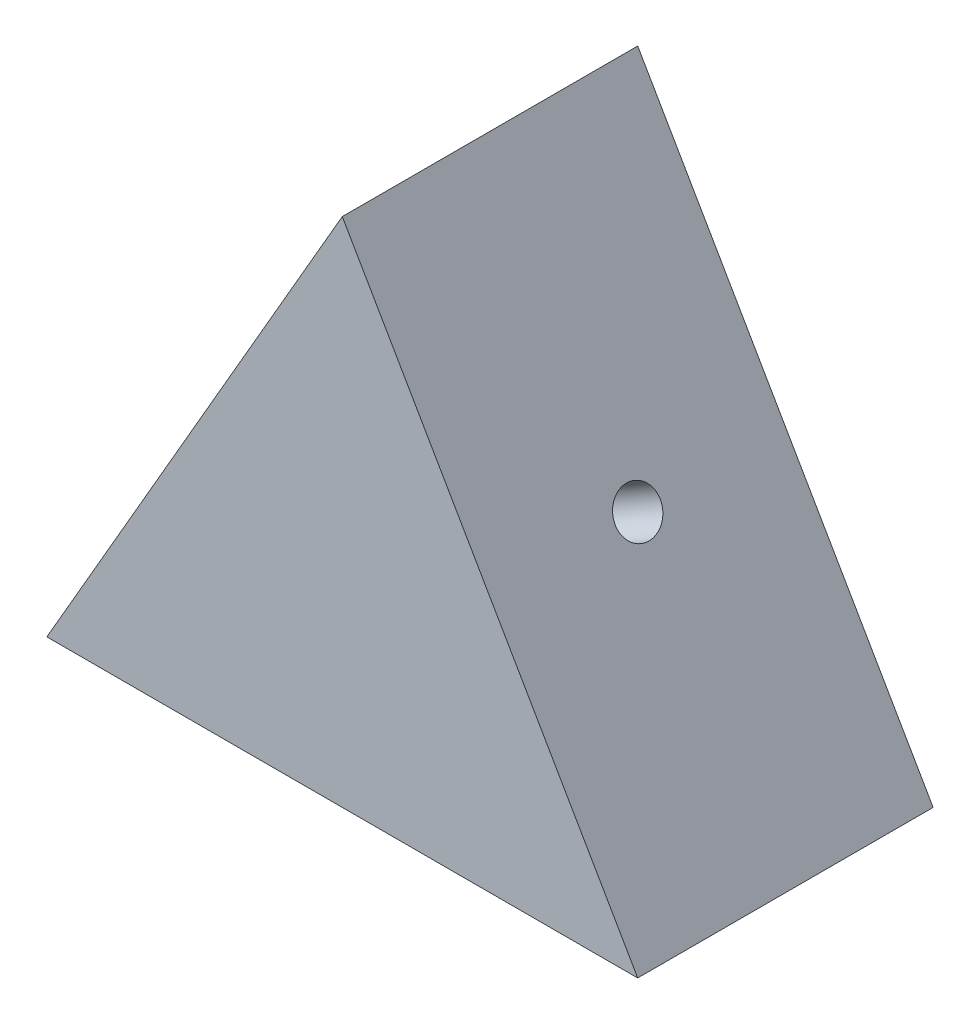
from build123d import *

# Parameters (mm, degrees)
BOSS_EXTRUDE1_DEPTH = 250
SKETCH2_R           = 19.05
CUT_EXTRUDE1_DEPTH  = 76.2
SKETCH3_R           = 19.05
CUT_EXTRUDE2_DEPTH  = 76.2
SKETCH4_R           = 19.05
CUT_EXTRUDE3_DEPTH  = 76.2


with BuildPart() as part:
    # Sketch1 → Boss-Extrude1 (new body)
    with BuildSketch(Plane.XY):
        Polygon((0, 0), (250, 0), (0, 433.012701892), (-250, 0), align=None)
    extrude(amount=BOSS_EXTRUDE1_DEPTH)

    # Sketch2 → Cut-Extrude1 (cut)
    with BuildSketch(Plane(origin=(187.5, 108.253175473, 0), x_dir=(0, 0, -1), z_dir=(0.866025404, 0.5, 0))):
        with Locations((-125, 125)):
            Circle(SKETCH2_R)
    extrude(amount=-CUT_EXTRUDE1_DEPTH, mode=Mode.SUBTRACT)

    # Sketch3 → Cut-Extrude2 (cut)
    with BuildSketch(Plane.XZ):
        with Locations((0, 125)):
            Circle(SKETCH3_R)
    extrude(amount=-CUT_EXTRUDE2_DEPTH, mode=Mode.SUBTRACT)

    # Sketch4 → Cut-Extrude3 (cut)
    with BuildSketch(Plane(origin=(-187.5, 108.253175473, 0), x_dir=(0, 0, 1), z_dir=(-0.866025404, 0.5, 0))):
        with Locations((125, 125)):
            Circle(SKETCH4_R)
    extrude(amount=-CUT_EXTRUDE3_DEPTH, mode=Mode.SUBTRACT)


solid = part.part
